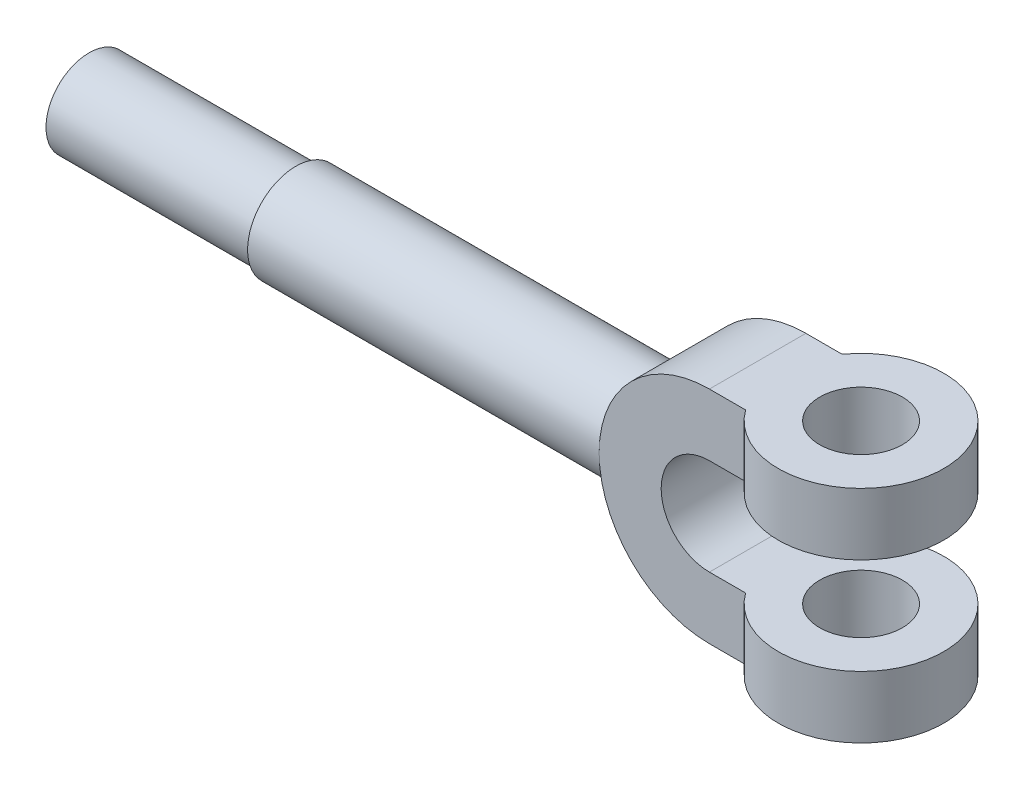
from build123d import *

# Parameters (mm, degrees)
BOSS_EXTRUDE1_DEPTH = 14
BOSS_EXTRUDE4_START = -60
SKETCH3_R           = 14
BOSS_EXTRUDE4_DEPTH = 104
SKETCH4_R           = 12.5
BOSS_EXTRUDE5_DEPTH = 60
SKETCH5_R           = 24
BOSS_EXTRUDE7_DEPTH = 18
SKETCH7_R           = 24
BOSS_EXTRUDE8_DEPTH = 18
CUT_EXTRUDE2_DEPTH  = 85
SKETCH10_R          = 12
CUT_EXTRUDE3_DEPTH  = 85


with BuildPart() as part:
    # Sketch2 → Boss-Extrude1 (new body, symmetric)
    with BuildSketch(Plane.XY):
        with BuildLine():
            Line((30, 14), (30, 32))
            Line((30, 32), (-30, 32))
            ThreePointArc((-30, 32), (-62, 0), (-30, -32))
            Line((-30, -32), (30, -32))
            Line((30, -32), (30, -14))
            Line((30, -14), (-30, -14))
            ThreePointArc((-30, -14), (-44, 0), (-30, 14))
            Line((-30, 14), (30, 14))
        make_face()
    extrude(amount=BOSS_EXTRUDE1_DEPTH, both=True)

    # Sketch3 → Boss-Extrude4 (add)
    with BuildSketch(Plane(origin=(0, 0, 0), x_dir=(0, 0, -1), z_dir=(1, 0, 0)).offset(BOSS_EXTRUDE4_START)):
        Circle(SKETCH3_R)
    extrude(amount=-BOSS_EXTRUDE4_DEPTH)

    # Sketch4 → Boss-Extrude5 (add)
    with BuildSketch(Plane.ZY.offset(164)):
        Circle(SKETCH4_R)
    extrude(amount=BOSS_EXTRUDE5_DEPTH)

    # Sketch5 → Boss-Extrude7 (add)
    with BuildSketch(Plane(origin=(0, 32, 0), x_dir=(1, 0, 0), z_dir=(0, 1, 0))):
        Circle(SKETCH5_R)
    extrude(amount=-BOSS_EXTRUDE7_DEPTH)

    # Sketch7 → Boss-Extrude8 (add)
    with BuildSketch(Plane.XZ.offset(32)):
        Circle(SKETCH7_R)
    extrude(amount=-BOSS_EXTRUDE8_DEPTH)

    # Sketch8 → Cut-Extrude2 (cut)
    with BuildSketch(Plane.XZ.offset(32)):
        with BuildLine():
            Line((19.49358869, -14), (30, -14))
            Line((30, -14), (30, 14))
            Line((30, 14), (19.49358869, 14))
            ThreePointArc((19.49358869, 14), (24, 0), (19.49358869, -14))
        make_face()
    extrude(amount=-CUT_EXTRUDE2_DEPTH, mode=Mode.SUBTRACT)

    # Sketch10 → Cut-Extrude3 (cut)
    with BuildSketch(Plane.XZ.offset(32)):
        Circle(SKETCH10_R)
    extrude(amount=-CUT_EXTRUDE3_DEPTH, mode=Mode.SUBTRACT)


solid = part.part
